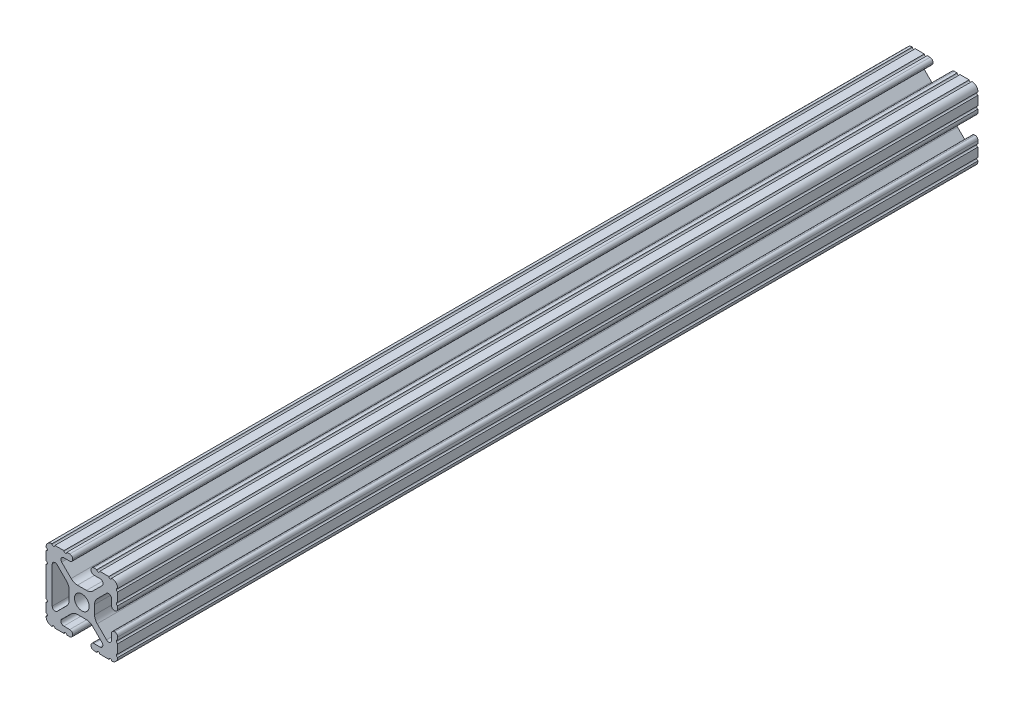
from build123d import *

# Parameters (mm, degrees)
SKETCH1_R           = 2.6035
BOSS_EXTRUDE1_DEPTH = 304.8


with BuildPart() as part:
    # Sketch1 → Boss-Extrude1 (new body)
    with BuildSketch(Plane(origin=(0, 0, -304.8), x_dir=(-1, 0, 0), z_dir=(0, 0, -1))):
        with BuildLine():
            Line((6.416409763, -10.4902), (4.28752, -10.4902))
            ThreePointArc((4.28752, -10.4902), (3.545750844, -10.797450844), (3.2385, -11.53922))
            Line((3.2385, -11.53922), (3.2385, -11.65098))
            ThreePointArc((3.2385, -11.65098), (3.545750844, -12.392749156), (4.28752, -12.7))
            Line((4.28752, -12.7), (5.3170836, -12.7))
            ThreePointArc((5.3170836, -12.7), (5.8250836, -12.192), (6.3330836, -12.7))
            Line((6.3330836, -12.7), (9.5504, -12.7))
            ThreePointArc((9.5504, -12.7), (10.058323491, -12.192000006), (10.566399977, -12.699846982))
            ThreePointArc((10.566399977, -12.699846982), (12.082522516, -12.082522516), (12.699846982, -10.566399977))
            ThreePointArc((12.699846982, -10.566399977), (12.192000006, -10.058323491), (12.7, -9.5504))
            Line((12.7, -9.5504), (12.7, -6.3330836))
            ThreePointArc((12.7, -6.3330836), (12.192, -5.8250836), (12.7, -5.3170836))
            Line((12.7, -5.3170836), (12.7, 5.3171344))
            ThreePointArc((12.7, 5.3171344), (12.192, 5.8251344), (12.7, 6.3331344))
            Line((12.7, 6.3331344), (12.7, 9.5504))
            ThreePointArc((12.7, 9.5504), (12.192000006, 10.058323491), (12.699846982, 10.566399977))
            ThreePointArc((12.699846982, 10.566399977), (12.082522516, 12.082522516), (10.566399977, 12.699846982))
            ThreePointArc((10.566399977, 12.699846982), (10.058323491, 12.192000006), (9.5504, 12.7))
            Line((9.5504, 12.7), (6.3331344, 12.7))
            ThreePointArc((6.3331344, 12.7), (5.8251344, 12.192), (5.3171344, 12.7))
            Line((5.3171344, 12.7), (4.2874692, 12.7))
            ThreePointArc((4.2874692, 12.7), (3.545700044, 12.392749156), (3.2384492, 11.65098))
            Line((3.2384492, 11.65098), (3.2384492, 11.53922))
            ThreePointArc((3.2384492, 11.53922), (3.545700044, 10.797450844), (4.2874692, 10.4902))
            Line((4.2874692, 10.4902), (6.416384363, 10.4902))
            ThreePointArc((6.416384363, 10.4902), (7.355223148, 9.862578342), (7.134149423, 8.755124678))
            Line((7.134149423, 8.755124678), (3.796632915, 5.423689619))
            ThreePointArc((3.796632915, 5.423689619), (2.767299421, 4.736928798), (1.553617102, 4.4958))
            Line((1.553617102, 4.4958), (-1.657299581, 4.4958))
            ThreePointArc((-1.657299581, 4.4958), (-2.8709819, 4.736928798), (-3.900315394, 5.423689619))
            Line((-3.900315394, 5.423689619), (-7.207191475, 8.724540082))
            ThreePointArc((-7.207191475, 8.724540082), (-7.43216212, 9.851515102), (-6.476774195, 10.4902))
            Line((-6.476774195, 10.4902), (-4.2874692, 10.4902))
            ThreePointArc((-4.2874692, 10.4902), (-3.545700044, 10.797450844), (-3.2384492, 11.53922))
            Line((-3.2384492, 11.53922), (-3.2384492, 11.65098))
            ThreePointArc((-3.2384492, 11.65098), (-3.545700044, 12.392749156), (-4.2874692, 12.7))
            Line((-4.2874692, 12.7), (-5.3170836, 12.7))
            ThreePointArc((-5.3170836, 12.7), (-5.8250836, 12.192), (-6.3330836, 12.7))
            Line((-6.3330836, 12.7), (-9.5504, 12.7))
            ThreePointArc((-9.5504, 12.7), (-10.058323491, 12.192000006), (-10.566399977, 12.699846982))
            ThreePointArc((-10.566399977, 12.699846982), (-12.082522516, 12.082522516), (-12.699846982, 10.566399977))
            ThreePointArc((-12.699846982, 10.566399977), (-12.192000006, 10.058323491), (-12.7, 9.5504))
            Line((-12.7, 9.5504), (-12.7, 6.3331344))
            ThreePointArc((-12.7, 6.3331344), (-12.192, 5.8251344), (-12.7, 5.3171344))
            Line((-12.7, 5.3171344), (-12.7, 4.287470133))
            ThreePointArc((-12.7, 4.287470133), (-12.392749156, 3.545700977), (-11.65098, 3.238450133))
            Line((-11.65098, 3.238450133), (-11.53922, 3.238450133))
            ThreePointArc((-11.53922, 3.238450133), (-10.797450844, 3.545700977), (-10.4902, 4.287470133))
            Line((-10.4902, 4.287470133), (-10.4902, 6.402089023))
            ThreePointArc((-10.4902, 6.402089023), (-9.856394933, 7.351113629), (-8.736962546, 7.129240479))
            Line((-8.736962546, 7.129240479), (-5.440484187, 3.838768792))
            ThreePointArc((-5.440484187, 3.838768792), (-4.75073678, 2.808015636), (-4.5085, 1.591658411))
            Line((-4.5085, 1.591658411), (-4.5085, -1.591658411))
            ThreePointArc((-4.5085, -1.591658411), (-4.75073678, -2.808015636), (-5.440484187, -3.838768792))
            Line((-5.440484187, -3.838768792), (-8.736962546, -7.129240479))
            ThreePointArc((-8.736962546, -7.129240479), (-9.856394933, -7.351113629), (-10.4902, -6.402089023))
            Line((-10.4902, -6.402089023), (-10.4902, -4.287470133))
            ThreePointArc((-10.4902, -4.287470133), (-10.797450844, -3.545700977), (-11.53922, -3.238450133))
            Line((-11.53922, -3.238450133), (-11.65098, -3.238450133))
            ThreePointArc((-11.65098, -3.238450133), (-12.392749156, -3.545700977), (-12.7, -4.287470133))
            Line((-12.7, -4.287470133), (-12.7, -5.3170836))
            ThreePointArc((-12.7, -5.3170836), (-12.192, -5.8250836), (-12.7, -6.3330836))
            Line((-12.7, -6.3330836), (-12.7, -9.5504))
            ThreePointArc((-12.7, -9.5504), (-12.192000006, -10.058323491), (-12.699846982, -10.566399977))
            ThreePointArc((-12.699846982, -10.566399977), (-12.082522516, -12.082522516), (-10.566399977, -12.699846982))
            ThreePointArc((-10.566399977, -12.699846982), (-10.058323491, -12.192000006), (-9.5504, -12.7))
            Line((-9.5504, -12.7), (-6.3331344, -12.7))
            ThreePointArc((-6.3331344, -12.7), (-5.8251344, -12.192), (-5.3171344, -12.7))
            Line((-5.3171344, -12.7), (-4.28752, -12.7))
            ThreePointArc((-4.28752, -12.7), (-3.545750844, -12.392749156), (-3.2385, -11.65098))
            Line((-3.2385, -11.65098), (-3.2385, -11.53922))
            ThreePointArc((-3.2385, -11.53922), (-3.545750844, -10.797450844), (-4.28752, -10.4902))
            Line((-4.28752, -10.4902), (-6.40834956, -10.4902))
            ThreePointArc((-6.40834956, -10.4902), (-7.350269456, -9.860518594), (-7.128470204, -8.749430454))
            Line((-7.128470204, -8.749430454), (-3.796658315, -5.423689619))
            ThreePointArc((-3.796658315, -5.423689619), (-2.767324821, -4.736928798), (-1.553642502, -4.4958))
            Line((-1.553642502, -4.4958), (1.553642502, -4.4958))
            ThreePointArc((1.553642502, -4.4958), (2.767324821, -4.736928798), (3.796658315, -5.423689619))
            Line((3.796658315, -5.423689619), (7.134174823, -8.755124678))
            ThreePointArc((7.134174823, -8.755124678), (7.355248548, -9.862578342), (6.416409763, -10.4902))
        make_face()
        Circle(SKETCH1_R, mode=Mode.SUBTRACT)
        with BuildLine():
            Line((10.4902, 6.446436794), (10.4902, -6.425372487))
            ThreePointArc((10.4902, -6.425372487), (9.862352148, -7.36547709), (8.753441447, -7.145689354))
            Line((8.753441447, -7.145689354), (5.440484187, -3.838768792))
            ThreePointArc((5.440484187, -3.838768792), (4.75073678, -2.808015636), (4.5085, -1.591658411))
            Line((4.5085, -1.591658411), (4.5085, 1.591658411))
            ThreePointArc((4.5085, 1.591658411), (4.75073678, 2.808015636), (5.440484187, 3.838768792))
            Line((5.440484187, 3.838768792), (8.768349738, 7.160570479))
            ThreePointArc((8.768349738, 7.160570479), (9.867741577, 7.378471563), (10.4902, 6.446436794))
        make_face(mode=Mode.SUBTRACT)
    extrude(amount=-BOSS_EXTRUDE1_DEPTH)


solid = part.part
